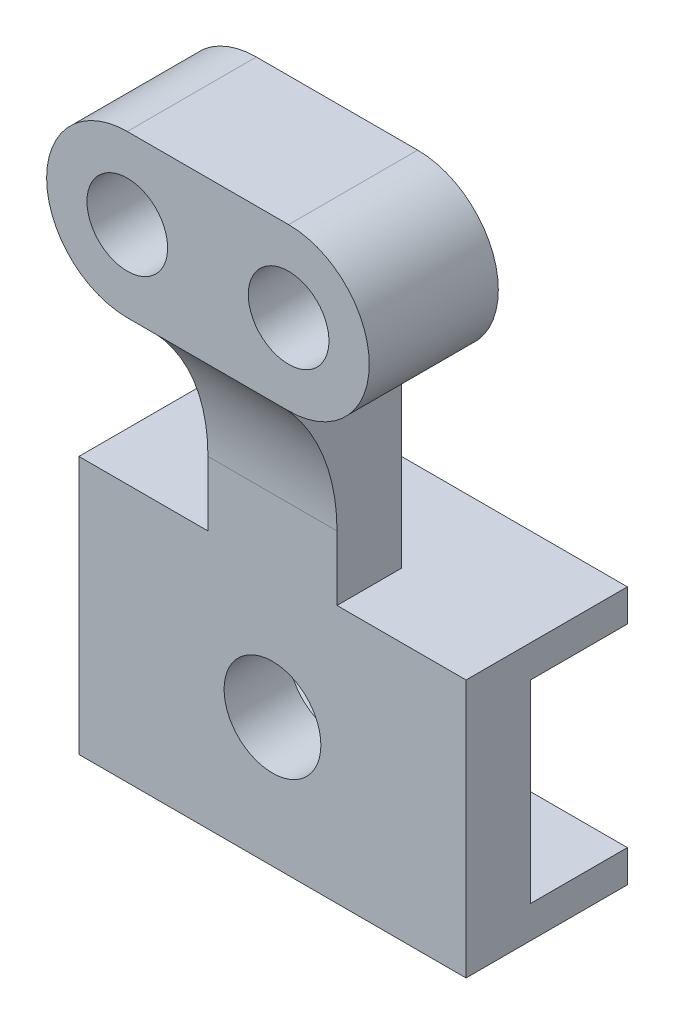
from build123d import *

# Parameters (mm, degrees)
BOSS_EXTRUDE1_DEPTH     = 38.1
SKETCH2_R               = 9.525
CUT_EXTRUDE1_DEPTH      = 1
CUT_EXTRUDE1_DEPTH_BACK = 32.75
BOSS_EXTRUDE2_DEPTH     = 12.7
SKETCH4_R               = 7.9375
BOSS_EXTRUDE3_DEPTH     = 25.4


with BuildPart() as part:
    # Sketch1 → Boss-Extrude1 (new body, symmetric)
    with BuildSketch(Plane.YZ):
        Polygon((0, 0), (0, 31.75), (-50.8, 31.75), (-50.8, 0), (-44.45, 0), (-44.45, 19.05), (-6.35, 19.05), (-6.35, 0), align=None)
    extrude(amount=BOSS_EXTRUDE1_DEPTH, both=True)

    # Sketch2 → Cut-Extrude1 (cut, two sides)
    with BuildSketch(Plane.XY.offset(31.75)) as cut_extrude1_sk:
        with Locations((0, -25.4)):
            Circle(SKETCH2_R)
    extrude(amount=CUT_EXTRUDE1_DEPTH, mode=Mode.SUBTRACT)
    extrude(cut_extrude1_sk.sketch, amount=-CUT_EXTRUDE1_DEPTH_BACK, mode=Mode.SUBTRACT)

    # Sketch3 → Boss-Extrude2 (add, symmetric)
    with BuildSketch(Plane.YZ):
        with BuildLine():
            Line((0, 19.05), (41.098063314, 19.05))
            Line((41.098063314, 19.05), (41.098063314, 44.45))
            ThreePointArc((41.098063314, 44.45), (28.254259867, 35.069617598), (12.7, 31.75))
            Line((12.7, 31.75), (0, 31.75))
            Line((0, 31.75), (0, 19.05))
        make_face()
    extrude(amount=BOSS_EXTRUDE2_DEPTH, both=True)

    # Sketch4 → Boss-Extrude3 (add)
    with BuildSketch(Plane(origin=(0, 0, 19.05), x_dir=(1, 0, 0), z_dir=(0, 0, -1))):
        with BuildLine():
            Line((-15.875, -41.098063314), (15.875, -41.098063314))
            ThreePointArc((15.875, -41.098063314), (31.75, -56.973063314), (15.875, -72.848063314))
            Line((15.875, -72.848063314), (-15.875, -72.848063314))
            ThreePointArc((-15.875, -72.848063314), (-31.75, -56.973063314), (-15.875, -41.098063314))
        make_face()
        with Locations((15.875, -56.973063314)):
            Circle(SKETCH4_R, mode=Mode.SUBTRACT)
        with Locations((-15.875, -56.973063314)):
            Circle(SKETCH4_R, mode=Mode.SUBTRACT)
    extrude(amount=-BOSS_EXTRUDE3_DEPTH)


solid = part.part
